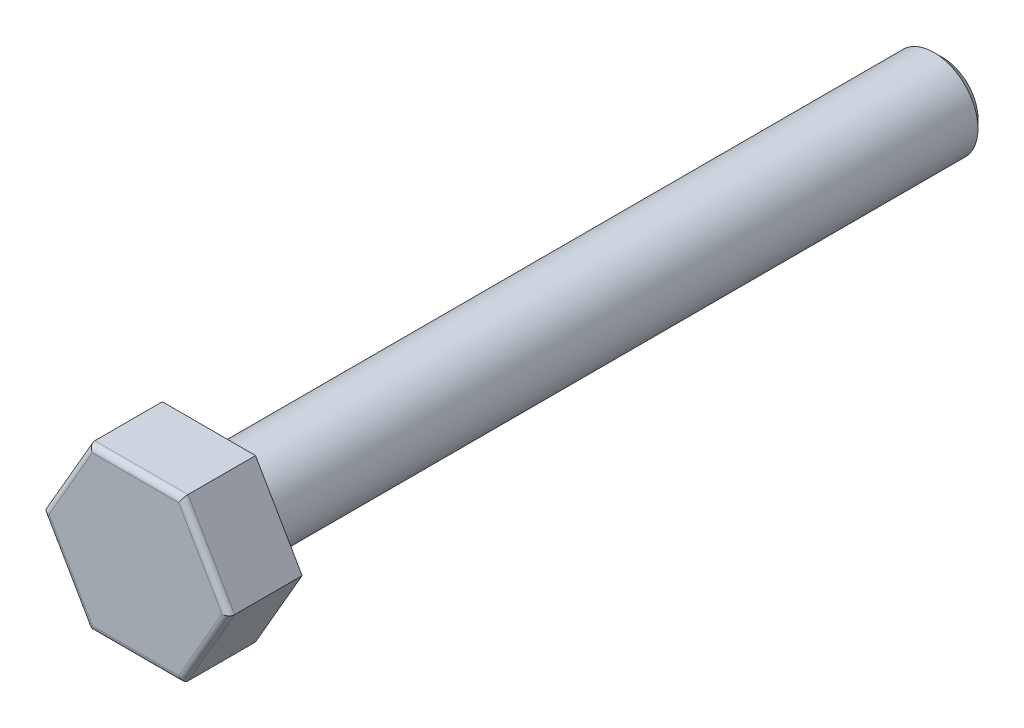
from build123d import *

# Parameters (mm, degrees)
BOSS_EXTRUDE1_DEPTH = 2.5
SKETCH2_R           = 1.5
BOSS_EXTRUDE2_DEPTH = 25
CHAMFER1_SIZE       = 0.3
FILLET1_R           = 0.2


with BuildPart() as part:
    # Sketch1 → Boss-Extrude1 (new body)
    with BuildSketch(Plane.XY):
        Polygon((3.175426481, 0), (1.58771324, 2.75), (-1.58771324, 2.75), (-3.175426481, 0), (-1.58771324, -2.75), (1.58771324, -2.75), align=None)
    extrude(amount=BOSS_EXTRUDE1_DEPTH)

    # Sketch2 → Boss-Extrude2 (add)
    with BuildSketch(Plane(origin=(0, 0, 0), x_dir=(-1, 0, 0), z_dir=(0, 0, -1))):
        Circle(SKETCH2_R)
    extrude(amount=BOSS_EXTRUDE2_DEPTH)

    # Chamfer1
    chamfer1_edges = [part.edges().sort_by_distance(p)[0] for p in [
        (1.5, 0, -25),
    ]]
    chamfer(chamfer1_edges, length=CHAMFER1_SIZE)

    # Fillet1
    fillet1_edges = [part.edges().sort_by_distance(p)[0] for p in [
        (0, 2.75, 2.5),
        (-2.38156986, 1.375, 2.5),
        (-2.38156986, -1.375, 2.5),
        (0, -2.75, 2.5),
        (2.38156986, -1.375, 2.5),
        (2.38156986, 1.375, 2.5),
    ]]
    fillet(fillet1_edges, radius=FILLET1_R)


solid = part.part
